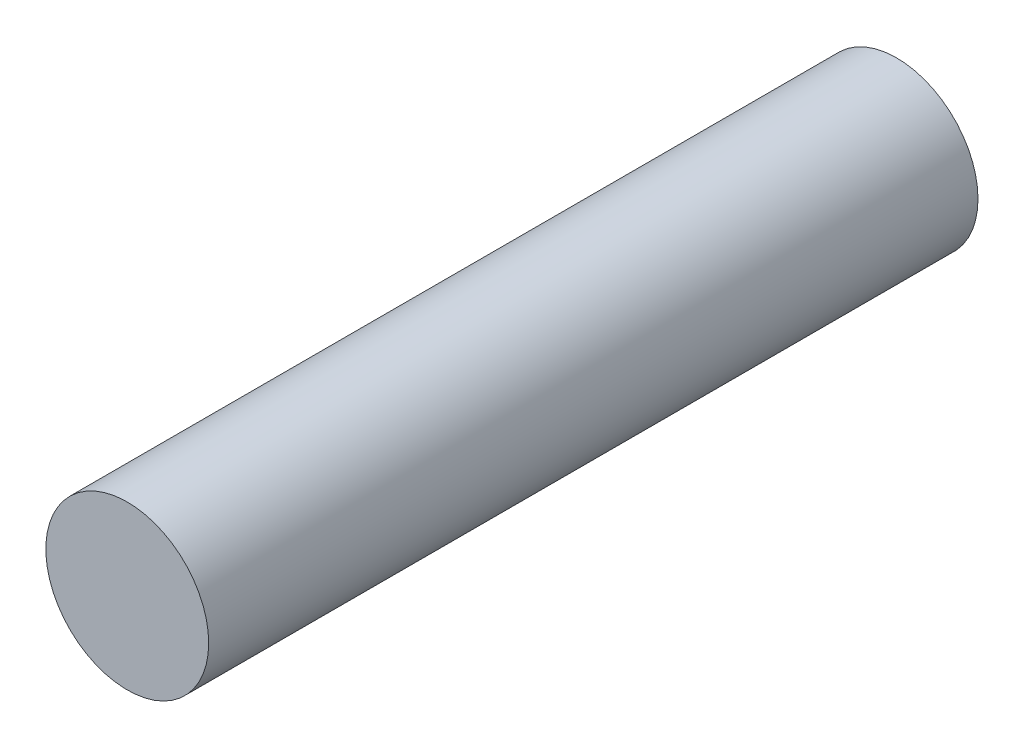
from build123d import *

# Parameters (mm, degrees)
BOSS_EXTRUDE1_DEPTH      = 60
BOSS_EXTRUDE1_DEPTH_BACK = 60
SKETCH1_R                = 12.7


with BuildPart() as part:
    # Sketch1 → Boss-Extrude1 (new, two sides: drawn at the far end of the back side and taken through both)
    with BuildSketch(Plane.XY.offset(-BOSS_EXTRUDE1_DEPTH_BACK)):
        Circle(SKETCH1_R)
    extrude(amount=BOSS_EXTRUDE1_DEPTH + BOSS_EXTRUDE1_DEPTH_BACK)


solid = part.part
